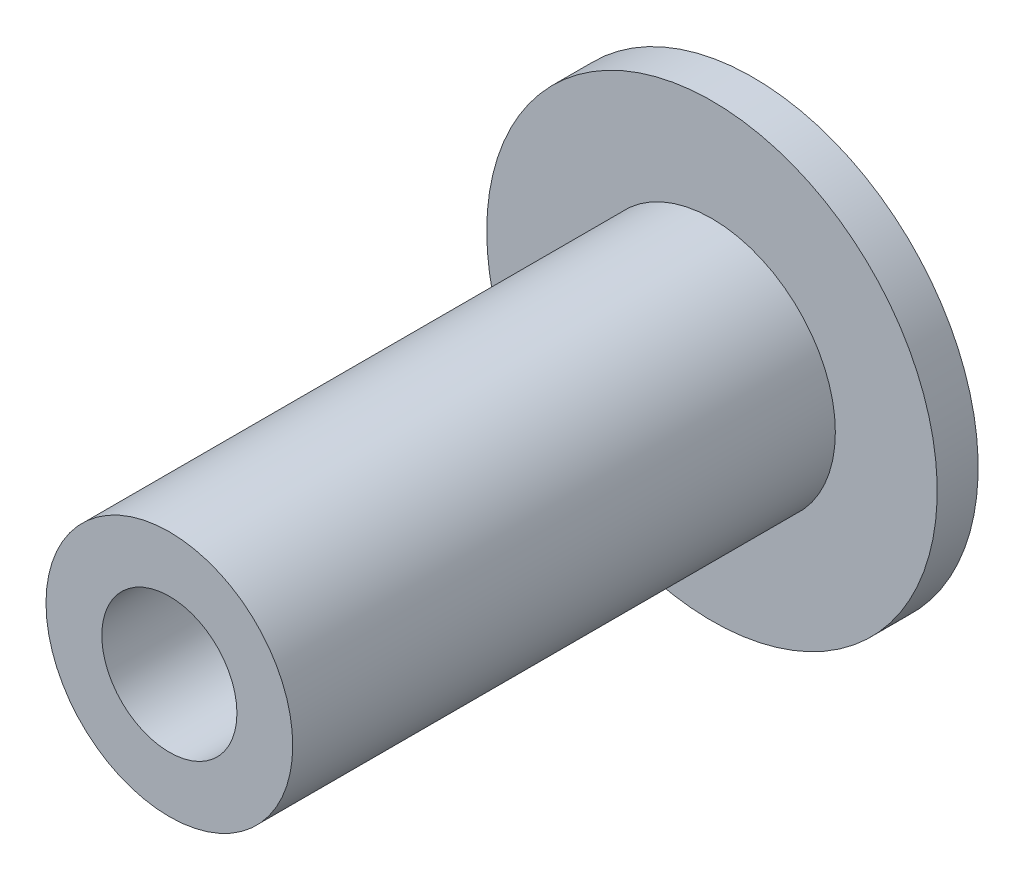
from build123d import *

# Parameters (mm, degrees)
SKETCH1_R           = 6.025
BOSS_EXTRUDE1_DEPTH = 10
SKETCH3_R           = 6.025
BOSS_EXTRUDE2_DEPTH = 16.5
SKETCH5_R           = 11
BOSS_EXTRUDE3_DEPTH = 2
SKETCH6_R           = 3.3
CUT_EXTRUDE3_DEPTH  = 29.5


with BuildPart() as part:
    # Sketch1 → Boss-Extrude1 (new body)
    with BuildSketch(Plane.XY):
        Circle(SKETCH1_R)
    extrude(amount=BOSS_EXTRUDE1_DEPTH)

    # Sketch3 → Boss-Extrude2 (add)
    with BuildSketch(Plane.XY.offset(10)):
        Circle(SKETCH3_R)
    extrude(amount=BOSS_EXTRUDE2_DEPTH)

    # Sketch5 → Boss-Extrude3 (add)
    with BuildSketch(Plane(origin=(0, 0, 0), x_dir=(-1, 0, 0), z_dir=(0, 0, -1))):
        Circle(SKETCH5_R)
    extrude(amount=BOSS_EXTRUDE3_DEPTH)

    # Sketch6 → Cut-Extrude3 (cut, through all)
    with BuildSketch(Plane.XY.offset(26.5)):
        Circle(SKETCH6_R)
    extrude(amount=-CUT_EXTRUDE3_DEPTH, mode=Mode.SUBTRACT)


solid = part.part
